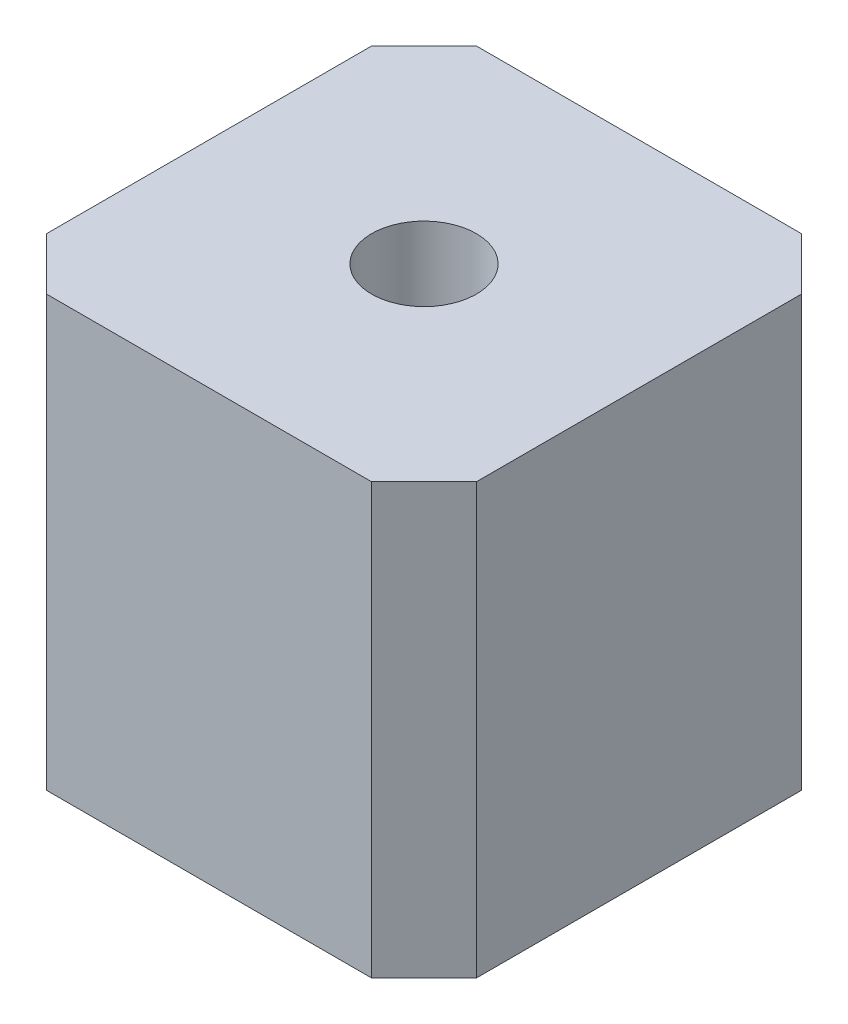
from build123d import *

# Parameters (mm, degrees)
SKETCH1_W           = 41
SKETCH1_H           = 41
BOSS_EXTRUDE1_DEPTH = 41
CHAMFER1_SIZE       = 5
SKETCH2_R           = 5
CUT_EXTRUDE1_DEPTH  = 42


with BuildPart() as part:
    # Sketch1 → Boss-Extrude1 (new body)
    with BuildSketch(Plane(origin=(0, 0, 0), x_dir=(1, 0, 0), z_dir=(0, 1, 0))):
        Rectangle(SKETCH1_W, SKETCH1_H)
    extrude(amount=BOSS_EXTRUDE1_DEPTH)

    # Chamfer1
    chamfer1_edges = [part.edges().sort_by_distance(p)[0] for p in [
        (20.5, 20.5, 20.5),
        (-20.5, 20.5, 20.5),
        (-20.5, 20.5, -20.5),
        (20.5, 20.5, -20.5),
    ]]
    chamfer(chamfer1_edges, length=CHAMFER1_SIZE)

    # Sketch2 → Cut-Extrude1 (cut, through all)
    with BuildSketch(Plane.XZ):
        Circle(SKETCH2_R)
    extrude(amount=-CUT_EXTRUDE1_DEPTH, mode=Mode.SUBTRACT)


solid = part.part
